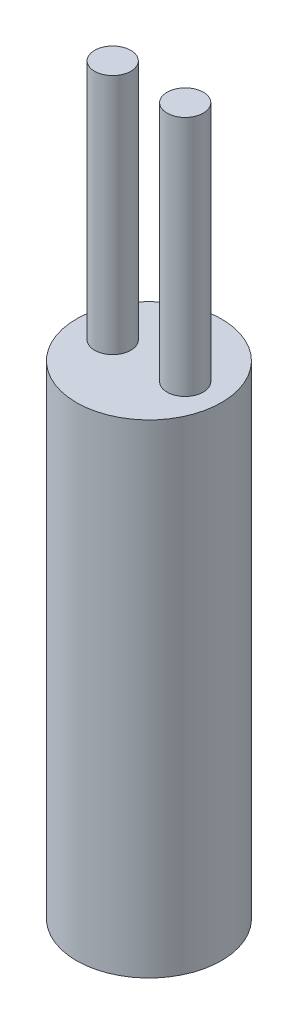
from build123d import *

# Parameters (mm, degrees)
SKETCH1_R           = 3
BOSS_EXTRUDE1_DEPTH = 20
SKETCH2_R           = 0.75
BOSS_EXTRUDE2_DEPTH = 10


with BuildPart() as part:
    # Sketch1 → Boss-Extrude1 (new body)
    with BuildSketch(Plane(origin=(0, 0, 0), x_dir=(1, 0, 0), z_dir=(0, 1, 0))):
        Circle(SKETCH1_R)
    extrude(amount=BOSS_EXTRUDE1_DEPTH)

    # Sketch2 → Boss-Extrude2 (add)
    with BuildSketch(Plane(origin=(0, 20, 0), x_dir=(1, 0, 0), z_dir=(0, 1, 0))):
        with Locations((1.5, 0)):
            Circle(SKETCH2_R)
        with Locations((-1.5, 0)):
            Circle(SKETCH2_R)
    extrude(amount=BOSS_EXTRUDE2_DEPTH)


solid = part.part
